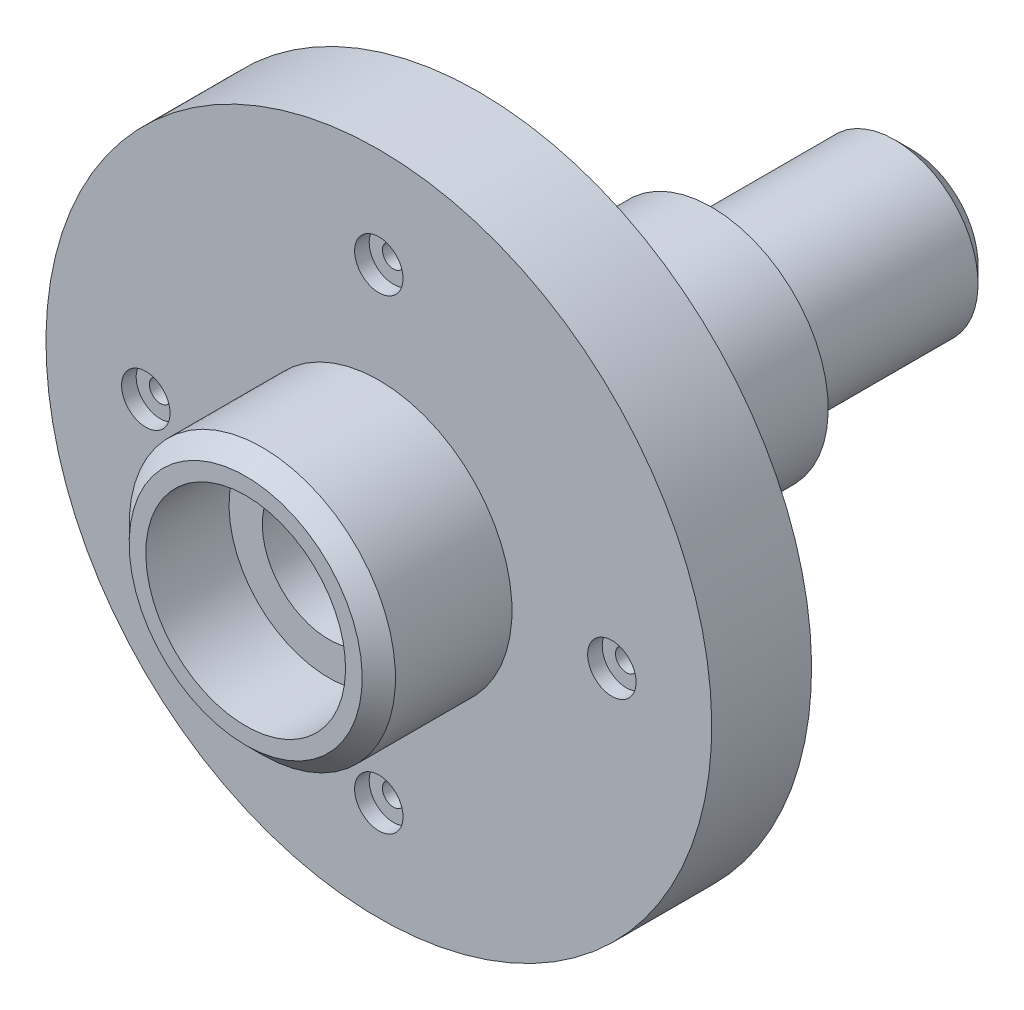
from build123d import *

# Parameters (mm, degrees)
CUT_EXTRUDE1_DEPTH                      = 10
CUT_EXTRUDE1_DEPTH_BACK                 = 10
SKETCH2_R                               = 30
CBORE_FOR_M6_HEX_HEAD_BOLT2_D           = 6.6
CBORE_FOR_M6_HEX_HEAD_BOLT2_CBORE_D     = 14.55
CBORE_FOR_M6_HEX_HEAD_BOLT2_CBORE_DEPTH = 4.38
CHAMFER1_SIZE                           = 5
M20X1_5_TAPPED_HOLE1_D                  = 18.5
M20X1_5_TAPPED_HOLE1_DEPTH              = 50
M20X1_5_TAPPED_HOLE1_TIP                = 5.557960726


with BuildPart() as part:
    # Sketch1 → Revolve1 (revolve)
    with BuildSketch(Plane(origin=(0, 0, 0), x_dir=(0, 0, -1), z_dir=(1, 0, 0))):
        Polygon((-200, 30), (-200, 40), (-160, 40), (-160, 100), (-130, 100), (-130, 35), (-60, 35), (-60, 25), (0, 25), (0, 0), (-155, 0), (-155, 20), (-175, 20), (-175, 30), align=None)
    revolve(axis=Axis((0, 0, 0), (0, 0, 1)))

    # Sketch2 → Cut-Extrude1 (cut, two sides: drawn at the far end of the back side and taken through both)
    with BuildSketch(Plane(origin=(0, 0, 0), x_dir=(0, 0, -1), z_dir=(1, 0, 0)).offset(-CUT_EXTRUDE1_DEPTH_BACK)):
        with Locations((-90, -50)):
            Circle(SKETCH2_R)
    extrude(amount=CUT_EXTRUDE1_DEPTH + CUT_EXTRUDE1_DEPTH_BACK, mode=Mode.SUBTRACT)

    # CBORE for M6 Hex Head Bolt2 (through all)
    with Locations(Plane(origin=(0, 70, 160), x_dir=(0, 1, 0), z_dir=(0, 0, 1))):
        with Locations((0, 0), (-70, -70), (-140, 0), (-70, 70)):
            CounterBoreHole(CBORE_FOR_M6_HEX_HEAD_BOLT2_D / 2, CBORE_FOR_M6_HEX_HEAD_BOLT2_CBORE_D / 2, CBORE_FOR_M6_HEX_HEAD_BOLT2_CBORE_DEPTH)

    # Chamfer1
    chamfer1_edges = [part.edges().sort_by_distance(p)[0] for p in [
        (0, -25, 0),
        (0, -40, 200),
    ]]
    chamfer(chamfer1_edges, length=CHAMFER1_SIZE)

    # M20x1.5 Tapped Hole1
    with Locations(Plane(origin=(0, 0, 0), x_dir=(0, -1, 0), z_dir=(0, 0, -1))):
        with Locations((0, 0)):
            Hole(M20X1_5_TAPPED_HOLE1_D / 2, depth=M20X1_5_TAPPED_HOLE1_DEPTH)
            with Locations((0, 0, -(M20X1_5_TAPPED_HOLE1_DEPTH + M20X1_5_TAPPED_HOLE1_TIP / 2))):  # 118° drill point
                Cone(0, M20X1_5_TAPPED_HOLE1_D / 2, M20X1_5_TAPPED_HOLE1_TIP, mode=Mode.SUBTRACT)


solid = part.part
